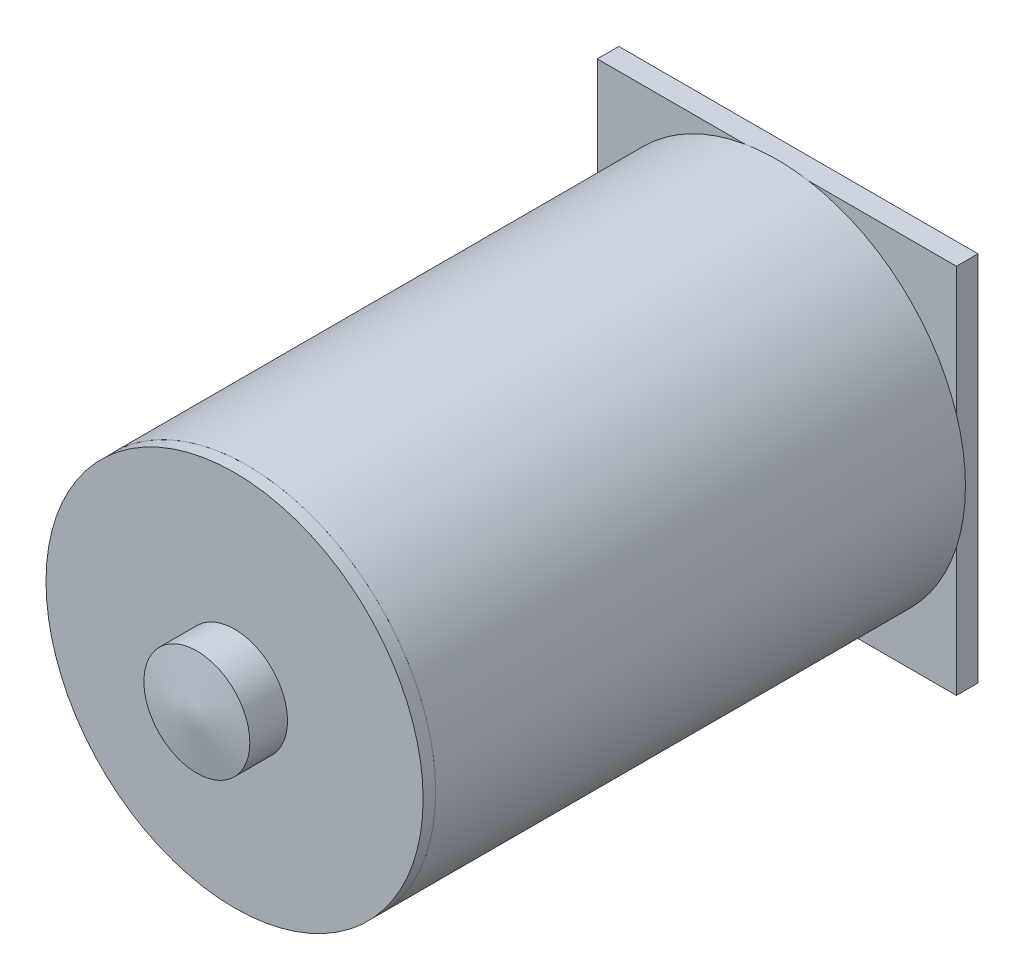
from build123d import *

# Parameters (mm, degrees)
SKETCH1_R           = 10.5
BOSS_EXTRUDE1_DEPTH = 29.5
SKETCH2_R           = 10.5
BOSS_EXTRUDE2_DEPTH = 0.7
SKETCH3_W           = 20
SKETCH3_H           = 20.7
BOSS_EXTRUDE3_DEPTH = 1.2
SKETCH4_R           = 3.85
CUT_EXTRUDE1_DEPTH  = 25
SKETCH5_R           = 2.95
BOSS_EXTRUDE4_DEPTH = 2.1
SKETCH6_R           = 2.95
BOSS_EXTRUDE5_DEPTH = 10
BOSS_EXTRUDE5_TAPER = 80


with BuildPart() as part:
    # Sketch1 → Boss-Extrude1 (new body)
    with BuildSketch(Plane.XY):
        Circle(SKETCH1_R)
    extrude(amount=BOSS_EXTRUDE1_DEPTH)

    # Sketch3 → Boss-Extrude3 (add)
    with BuildSketch(Plane(origin=(0, 0, 0), x_dir=(-1, 0, 0), z_dir=(0, 0, -1))):
        Rectangle(SKETCH3_W, SKETCH3_H)
    extrude(amount=BOSS_EXTRUDE3_DEPTH)

    # Sketch4 → Cut-Extrude1 (cut)
    with BuildSketch(Plane(origin=(0, 0, -1.2), x_dir=(-1, 0, 0), z_dir=(0, 0, -1))):
        Circle(SKETCH4_R)
    extrude(amount=-CUT_EXTRUDE1_DEPTH, mode=Mode.SUBTRACT)


with BuildPart() as body_2:
    # Sketch2 → Boss-Extrude2 (new body)
    with BuildSketch(Plane.XY.offset(29.5)):
        Circle(SKETCH2_R)
    extrude(amount=BOSS_EXTRUDE2_DEPTH)

    # Sketch5 → Boss-Extrude4 (add)
    with BuildSketch(Plane.XY.offset(30.2)):
        Circle(SKETCH5_R)
    extrude(amount=BOSS_EXTRUDE4_DEPTH)

    # Sketch6 → Boss-Extrude5 (add)
    with BuildSketch(Plane.XY.offset(32.3)):
        Circle(SKETCH6_R)
    extrude(amount=BOSS_EXTRUDE5_DEPTH, taper=BOSS_EXTRUDE5_TAPER)


solid = Compound([part.part, body_2.part])
